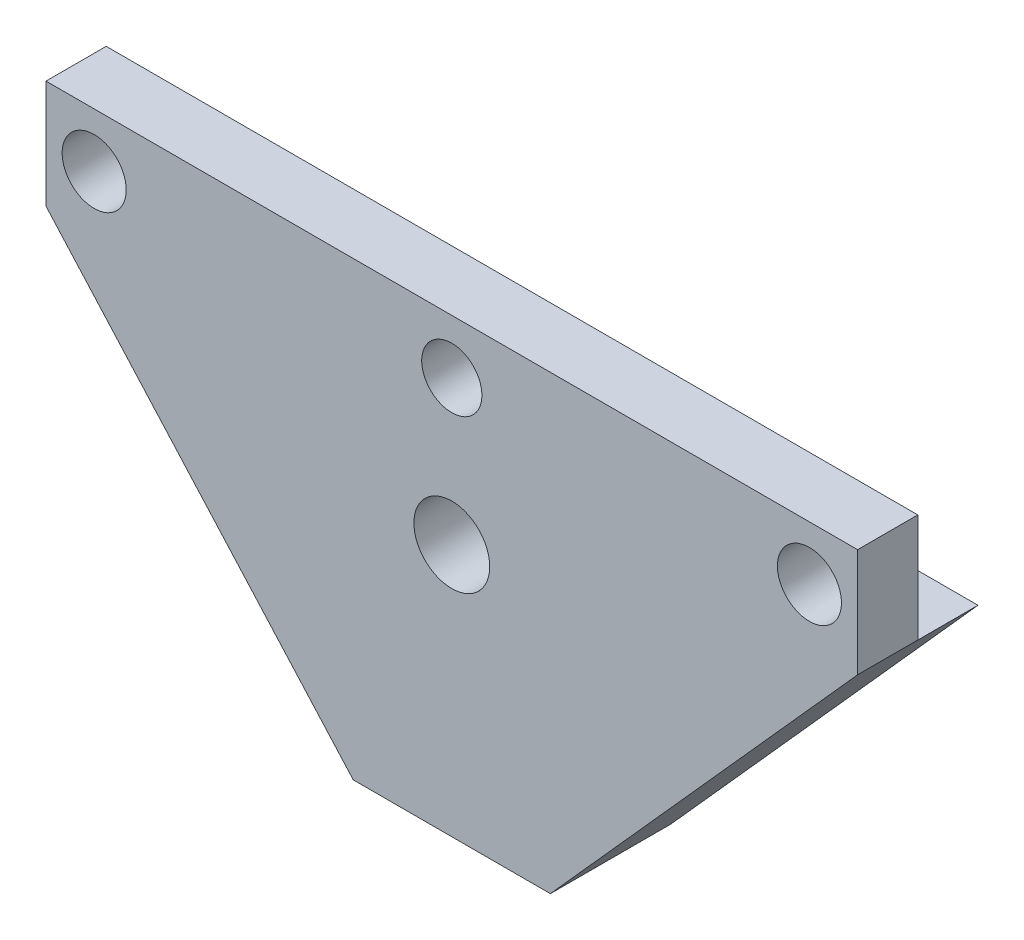
from build123d import *

# Parameters (mm, degrees)
BOSS_EXTRUDE1_DEPTH     = 12.7
SKETCH2_R               = 3.175
CUT_EXTRUDE1_DEPTH      = 13.7
SKETCH3_W               = 6.35
SKETCH3_H               = 11.43
CUT_EXTRUDE2_DEPTH      = 86.600261098
SKETCH4_R               = 4
CUT_EXTRUDE3_DEPTH      = 13.7
F_1_4_CLEARANCE_HOLE1_D = 6.7564


with BuildPart() as part:
    # Sketch1 → Boss-Extrude1 (new body)
    with BuildSketch(Plane.XY):
        Polygon((-42.800130549, -5.715), (-10.39539802, -41.91), (10.39539802, -41.91), (42.800130549, -5.715), (42.800130549, 5.715), (-42.800130549, 5.715), align=None)
    extrude(amount=-BOSS_EXTRUDE1_DEPTH)

    # Sketch2 → Cut-Extrude1 (cut, through all)
    with BuildSketch(Plane.XY):
        Circle(SKETCH2_R)
    extrude(amount=-CUT_EXTRUDE1_DEPTH, mode=Mode.SUBTRACT)

    # Sketch3 → Cut-Extrude2 (cut, through all)
    with BuildSketch(Plane(origin=(42.800130549, 0, 0), x_dir=(0, 0, -1), z_dir=(1, 0, 0))):
        with Locations((9.525, 0)):
            Rectangle(SKETCH3_W, SKETCH3_H)
    extrude(amount=-CUT_EXTRUDE2_DEPTH, mode=Mode.SUBTRACT)

    # Sketch4 → Cut-Extrude3 (cut, through all)
    with BuildSketch(Plane.XY):
        with Locations((0, -15.24)):
            Circle(SKETCH4_R)
    extrude(amount=-CUT_EXTRUDE3_DEPTH, mode=Mode.SUBTRACT)

    # 1/4 Clearance Hole1 (through all)
    with Locations(Plane(origin=(0, 0, -6.35), x_dir=(-1, 0, 0), z_dir=(0, 0, -1))):
        with Locations((-37.720130549, 0), (37.720130549, 0)):
            Hole(F_1_4_CLEARANCE_HOLE1_D / 2)


solid = part.part
